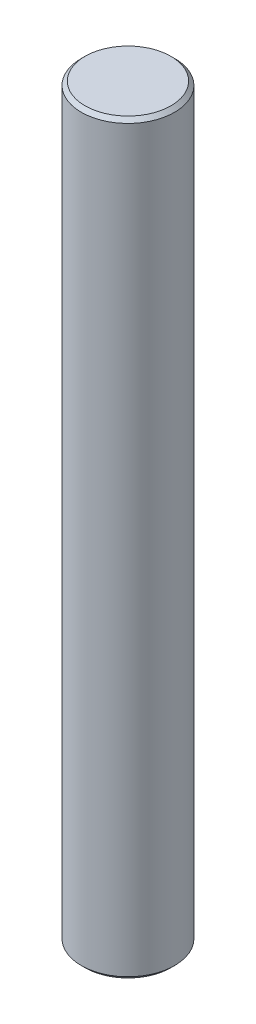
from build123d import *

# Parameters (mm, degrees)
SKETCH1_R           = 12.5
BOSS_EXTRUDE1_DEPTH = 200
CHAMFER1_SIZE       = 1


with BuildPart() as part:
    # Sketch1 → Boss-Extrude1 (new body)
    with BuildSketch(Plane(origin=(0, 0, 0), x_dir=(1, 0, 0), z_dir=(0, 1, 0))):
        Circle(SKETCH1_R)
    extrude(amount=BOSS_EXTRUDE1_DEPTH)

    # Chamfer1
    chamfer1_edges = [part.edges().sort_by_distance(p)[0] for p in [
        (-12.5, 0, 0),
        (-12.5, 200, 0),
    ]]
    chamfer(chamfer1_edges, length=CHAMFER1_SIZE)


solid = part.part
